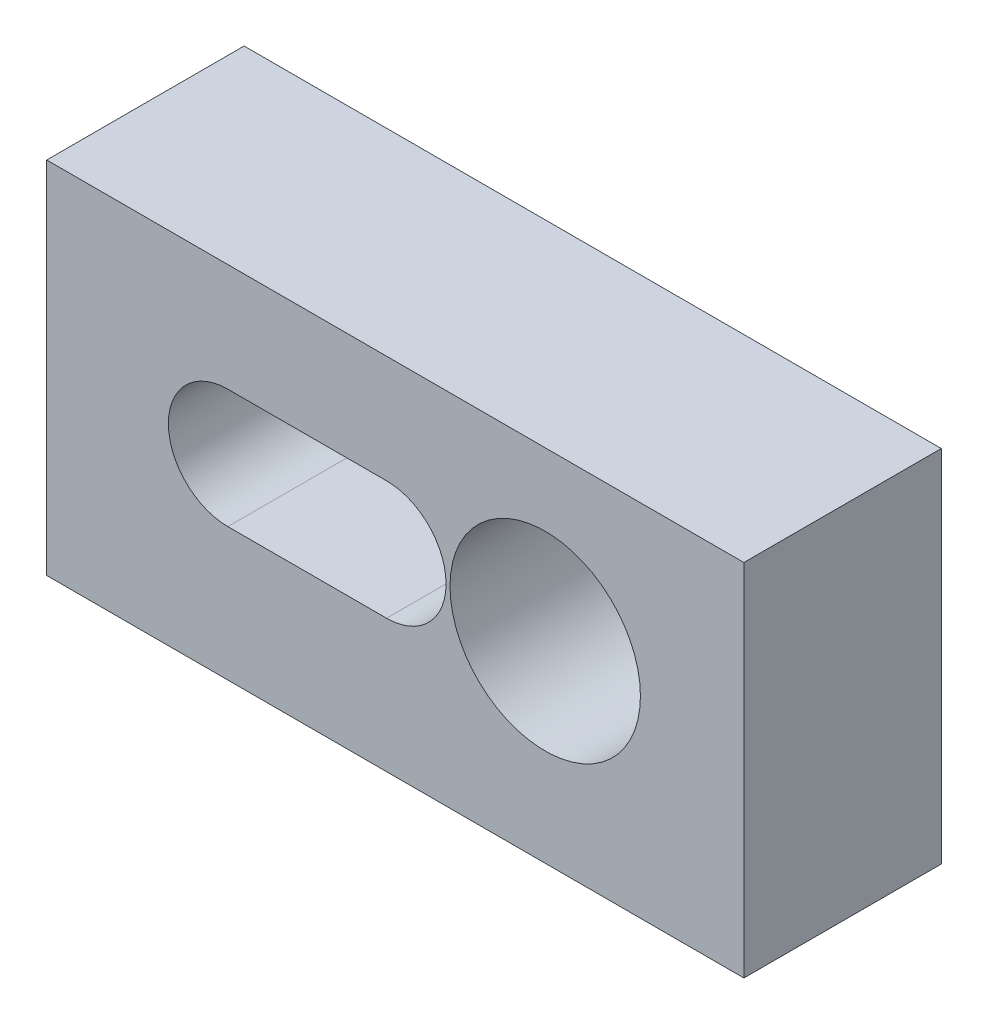
from build123d import *

# Parameters (mm, degrees)
SKETCH1_W           = 55.8
SKETCH1_H           = 15.8
BOSS_EXTRUDE1_DEPTH = 28.8
SKETCH2_R           = 7.62
CUT_EXTRUDE1_DEPTH  = 12.7
SKETCH4_R           = 2.778125
SKETCH4_R_2         = 1.8415
CUT_EXTRUDE2_DEPTH  = 12.7
CUT_EXTRUDE6_DEPTH  = 1.905


with BuildPart() as part:
    # Sketch1 → Boss-Extrude1 (new body)
    with BuildSketch(Plane(origin=(0, 0, 0), x_dir=(1, 0, 0), z_dir=(0, 1, 0))):
        with Locations((-11.199948696, 8.193463303)):
            Rectangle(SKETCH1_W, SKETCH1_H)
    extrude(amount=BOSS_EXTRUDE1_DEPTH)

    # Sketch2 → Cut-Extrude1 (cut)
    with BuildSketch(Plane.XY.offset(-0.293463303)):
        with Locations((0.800051304, 15.4)):
            Circle(SKETCH2_R)
        with BuildLine():
            Line((-11.899948696, 10.6375), (-24.599948696, 10.6375))
            ThreePointArc((-24.599948696, 10.6375), (-29.362448696, 15.4), (-24.599948696, 20.1625))
            Line((-24.599948696, 20.1625), (-11.899948696, 20.1625))
            ThreePointArc((-11.899948696, 20.1625), (-7.137448696, 15.4), (-11.899948696, 10.6375))
        make_face()
    extrude(amount=-CUT_EXTRUDE1_DEPTH, mode=Mode.SUBTRACT)

    # Sketch4 → Cut-Extrude2 (cut)
    with BuildSketch(Plane(origin=(0, 0, -16.093463303), x_dir=(-1, 0, 0), z_dir=(0, 0, -1))):
        with Locations((-0.800051304, 15.4)):
            Circle(SKETCH4_R)
        with Locations((11.899948696, 15.4)):
            Circle(SKETCH4_R_2)
        with Locations((24.599948696, 15.4)):
            Circle(SKETCH4_R_2)
    extrude(amount=-CUT_EXTRUDE2_DEPTH, mode=Mode.SUBTRACT)

    # Sketch5 → Cut-Extrude6 (cut)
    with BuildSketch(Plane(origin=(0, 0, -16.093463303), x_dir=(-1, 0, 0), z_dir=(0, 0, -1))):
        with BuildLine():
            Line((24.599948696, 20.1625), (11.899948696, 20.1625))
            ThreePointArc((11.899948696, 20.1625), (7.137448696, 15.4), (11.899948696, 10.6375))
            Line((11.899948696, 10.6375), (24.599948696, 10.6375))
            ThreePointArc((24.599948696, 10.6375), (29.362448696, 15.4), (24.599948696, 20.1625))
        make_face()
    extrude(amount=-CUT_EXTRUDE6_DEPTH, mode=Mode.SUBTRACT)


solid = part.part
